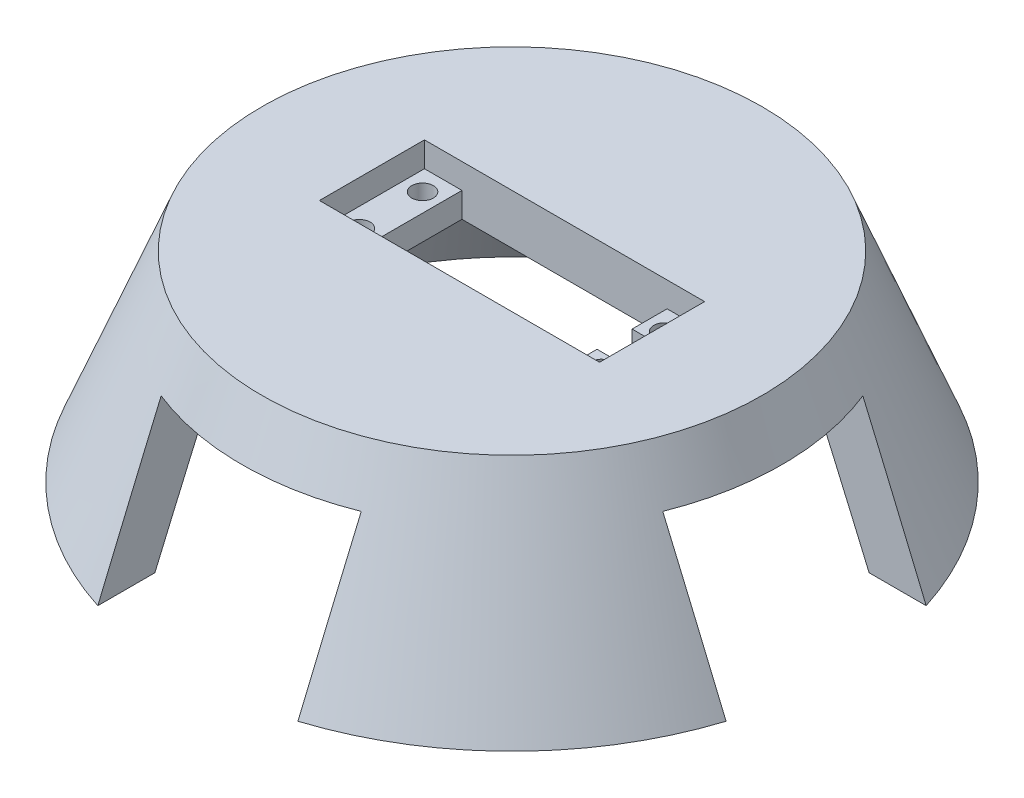
from build123d import *

# Parameters (mm, degrees)
SHELL1_T                = -10
SKETCH4_W               = 41
SKETCH4_H               = 21
CUT_EXTRUDE1_DEPTH      = 10
SKETCH5_W               = 7.5
SKETCH5_H               = 21
CUT_EXTRUDE2_DEPTH      = 5
SKETCH6_R               = 2.16
CUT_EXTRUDE3_DEPTH      = 5
MIRROR1_COPY_1_SKETCH_R = 2.16
MIRROR1_COPY_1_DEPTH    = 5
SKETCH7_W               = 4
SKETCH7_H               = 3.5
CUT_EXTRUDE4_DEPTH      = 10
CUT_EXTRUDE7_DEPTH      = 30


with BuildPart() as part:
    # Sketch2 → Revolve1 (revolve)
    with BuildSketch(Plane.XY, mode=Mode.PRIVATE) as revolve1_sk:
        Polygon((0, 0), (0, 40), (-50, 40), (-65.896319649, 0), align=None)
    revolve(revolve1_sk.sketch.rotate(Axis((0, 0, 0), (0, 1, 0)), 270), axis=Axis((0, 0, 0), (0, 1, 0)))

    # Shell1
    shell1_openings = [part.faces().sort_by_distance(p)[0] for p in [
        (0, 0, 0),
    ]]
    offset(amount=SHELL1_T, openings=shell1_openings, kind=Kind.INTERSECTION)

    # Sketch4 → Cut-Extrude1 (cut)
    with BuildSketch(Plane(origin=(0, 40, 0), x_dir=(1, 0, 0), z_dir=(0, 1, 0))):
        Rectangle(SKETCH4_W, SKETCH4_H)
    extrude(amount=-CUT_EXTRUDE1_DEPTH, mode=Mode.SUBTRACT)

    # Sketch5 → Cut-Extrude2 (cut)
    with BuildSketch(Plane(origin=(0, 40, 0), x_dir=(1, 0, 0), z_dir=(0, 1, 0))):
        with Locations((-24.25, 0)):
            Rectangle(SKETCH5_W, SKETCH5_H)
    cut_extrude2 = extrude(amount=-CUT_EXTRUDE2_DEPTH, mode=Mode.SUBTRACT)

    # Sketch6 → Cut-Extrude3 (cut)
    with BuildSketch(Plane(origin=(0, 35, 0), x_dir=(1, 0, 0), z_dir=(0, 1, 0))):
        with Locations(Location((-24.19, 6.31, 0), (0, 0, 270))):
            Circle(SKETCH6_R)
    cut_extrude3 = extrude(amount=-CUT_EXTRUDE3_DEPTH, mode=Mode.SUBTRACT)

    # Mirror2: Cut-Extrude3 across plane
    add(cut_extrude3.mirror(Plane.XY), mode=Mode.SUBTRACT)

    # Mirror1: Cut-Extrude2, Cut-Extrude3 across plane
    add(cut_extrude2.mirror(Plane(origin=(0, 0, 0), x_dir=(0, 0, 1), z_dir=(1, 0, 0))), mode=Mode.SUBTRACT)
    add(cut_extrude3.mirror(Plane(origin=(0, 0, 0), x_dir=(0, 0, 1), z_dir=(1, 0, 0))), mode=Mode.SUBTRACT)

    # Mirror1 copy 1 sketch → Mirror1 copy 1 (cut)
    with BuildSketch(Plane(origin=(0, 35, 0), x_dir=(-1, 0, 0), z_dir=(0, 1, 0))):
        with Locations(Location((-24.19, 6.31, 0), (0, 0, 270))):
            Circle(MIRROR1_COPY_1_SKETCH_R)
    extrude(amount=-MIRROR1_COPY_1_DEPTH, mode=Mode.SUBTRACT)

    # Sketch7 → Cut-Extrude4 (cut)
    with BuildSketch(Plane(origin=(0, 35, 0), x_dir=(1, 0, 0), z_dir=(0, 1, 0))):
        with Locations((22.5, -1.75)):
            Rectangle(SKETCH7_W, SKETCH7_H)
    cut_extrude4 = extrude(amount=-CUT_EXTRUDE4_DEPTH, mode=Mode.SUBTRACT)

    # Mirror3: Cut-Extrude4 across plane
    add(cut_extrude4.mirror(Plane.XY), mode=Mode.SUBTRACT)

    # Sketch8 → Cut-Extrude7 (cut)
    with BuildSketch(Plane.XZ):
        with BuildLine():
            Line((-20, 51.38028066), (-20, 20))
            Line((-20, 20), (20, 20))
            Line((20, 20), (20, 51.38028066))
            ThreePointArc((20, 51.38028066), (0, 55.135589602), (-20, 51.38028066))
        make_face()
        with BuildLine():
            Line((-20, -51.38028066), (-20, -62.787936288))
            ThreePointArc((-20, -62.787936288), (0, -65.896319649), (20, -62.787936288))
            Line((20, -62.787936288), (20, -51.38028066))
            ThreePointArc((20, -51.38028066), (0, -55.135589602), (-20, -51.38028066))
        make_face()
        with BuildLine():
            ThreePointArc((20, 62.787936288), (0, 65.896319649), (-20, 62.787936288))
            Line((-20, 62.787936288), (-20, 51.38028066))
            ThreePointArc((-20, 51.38028066), (0, 55.135589602), (20, 51.38028066))
            Line((20, 51.38028066), (20, 62.787936288))
        make_face()
        with BuildLine():
            Line((-51.38028066, -20), (-20, -20))
            Line((-20, -20), (-20, 20))
            Line((-20, 20), (-51.38028066, 20))
            ThreePointArc((-51.38028066, 20), (-55.135589602, 0), (-51.38028066, -20))
        make_face()
        with BuildLine():
            ThreePointArc((-62.787936288, 20), (-65.896319649, 0), (-62.787936288, -20))
            Line((-62.787936288, -20), (-51.38028066, -20))
            ThreePointArc((-51.38028066, -20), (-55.135589602, 0), (-51.38028066, 20))
            Line((-51.38028066, 20), (-62.787936288, 20))
        make_face()
        with BuildLine():
            Line((51.38028066, -20), (62.787936288, -20))
            ThreePointArc((62.787936288, -20), (65.114586933, -10.12005493), (65.896319649, 0))
            ThreePointArc((65.896319649, 0), (65.114586933, 10.12005493), (62.787936288, 20))
            Line((62.787936288, 20), (51.38028066, 20))
            ThreePointArc((51.38028066, 20), (54.188630306, 10.174752396), (55.135589602, 0))
            ThreePointArc((55.135589602, 0), (54.188630306, -10.174752396), (51.38028066, -20))
        make_face()
        with BuildLine():
            Line((-20, -20), (-20, -51.38028066))
            ThreePointArc((-20, -51.38028066), (0, -55.135589602), (20, -51.38028066))
            Line((20, -51.38028066), (20, -20))
            Line((20, -20), (-20, -20))
        make_face()
        with BuildLine():
            Line((20, 20), (20, -20))
            Line((20, -20), (51.38028066, -20))
            ThreePointArc((51.38028066, -20), (54.188630306, -10.174752396), (55.135589602, 0))
            ThreePointArc((55.135589602, 0), (54.188630306, 10.174752396), (51.38028066, 20))
            Line((51.38028066, 20), (20, 20))
        make_face()
    extrude(amount=-CUT_EXTRUDE7_DEPTH, mode=Mode.SUBTRACT)


solid = part.part
